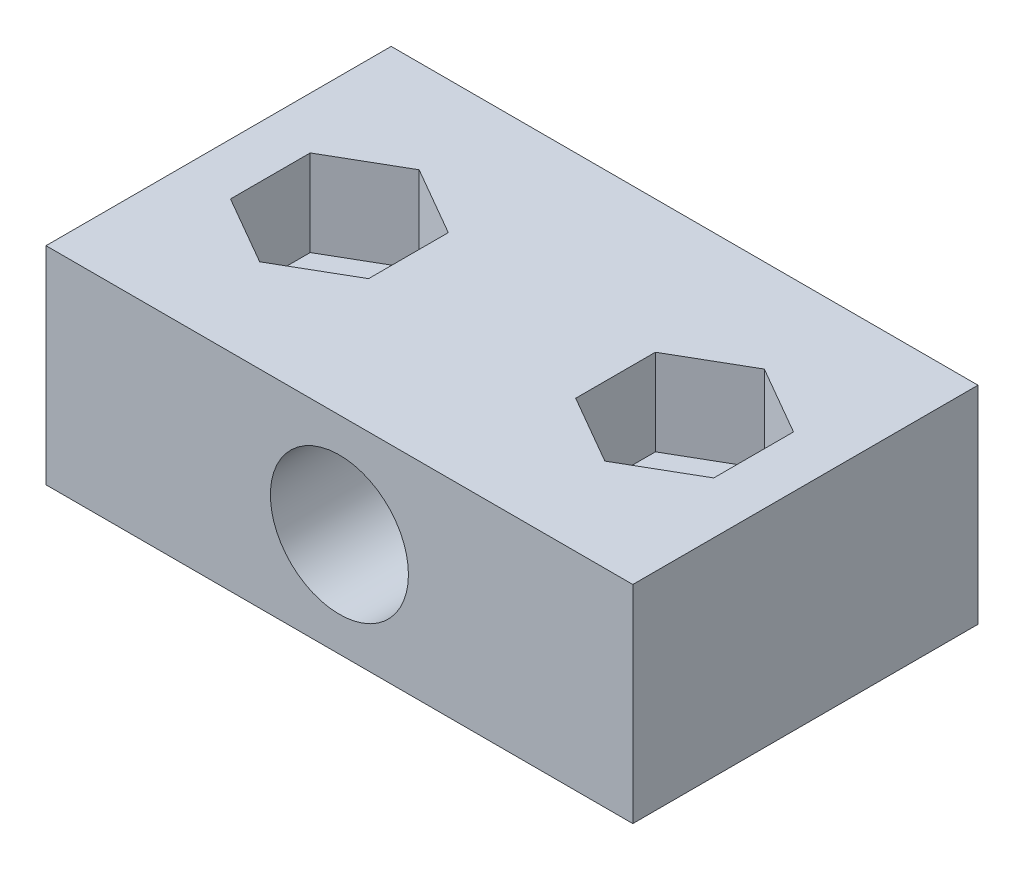
from build123d import *

# Parameters (mm, degrees)
SKETCH1_W           = 34
SKETCH1_H           = 12
BOSS_EXTRUDE1_DEPTH = 20
SKETCH2_R           = 4
CUT_EXTRUDE1_DEPTH  = 21
SKETCH3_R           = 2.55
CUT_EXTRUDE2_DEPTH  = 13
CUT_EXTRUDE3_DEPTH  = 5
SKETCH5_R           = 4.5
CUT_EXTRUDE4_DEPTH  = 2


with BuildPart() as part:
    # Sketch1 → Boss-Extrude1 (new body)
    with BuildSketch(Plane.XY):
        Rectangle(SKETCH1_W, SKETCH1_H)
    extrude(amount=BOSS_EXTRUDE1_DEPTH)

    # Sketch2 → Cut-Extrude1 (cut, through all)
    with BuildSketch(Plane.XY.offset(20)):
        Circle(SKETCH2_R)
    extrude(amount=-CUT_EXTRUDE1_DEPTH, mode=Mode.SUBTRACT)

    # Sketch3 → Cut-Extrude2 (cut, through all)
    with BuildSketch(Plane(origin=(0, 6, 0), x_dir=(1, 0, 0), z_dir=(0, 1, 0))):
        with Locations((-10, -10)):
            Circle(SKETCH3_R)
        with Locations((10, -10)):
            Circle(SKETCH3_R)
    extrude(amount=-CUT_EXTRUDE2_DEPTH, mode=Mode.SUBTRACT)

    # Sketch4 → Cut-Extrude3 (cut)
    with BuildSketch(Plane(origin=(0, 6, 0), x_dir=(1, 0, 0), z_dir=(0, 1, 0))):
        Polygon((-10, -5.381197846), (-14, -7.690598923), (-14, -12.309401077), (-10, -14.618802154), (-6, -12.309401077), (-6, -7.690598923), align=None)
        Polygon((6, -7.690598923), (10, -5.381197846), (14, -7.690598923), (14, -12.309401077), (10, -14.618802154), (6, -12.309401077), align=None)
    extrude(amount=-CUT_EXTRUDE3_DEPTH, mode=Mode.SUBTRACT)

    # Sketch5 → Cut-Extrude4 (cut)
    with BuildSketch(Plane.XZ.offset(6)):
        with Locations((10, 10)):
            Circle(SKETCH5_R)
        with Locations((-10, 10)):
            Circle(SKETCH5_R)
    extrude(amount=-CUT_EXTRUDE4_DEPTH, mode=Mode.SUBTRACT)


solid = part.part
